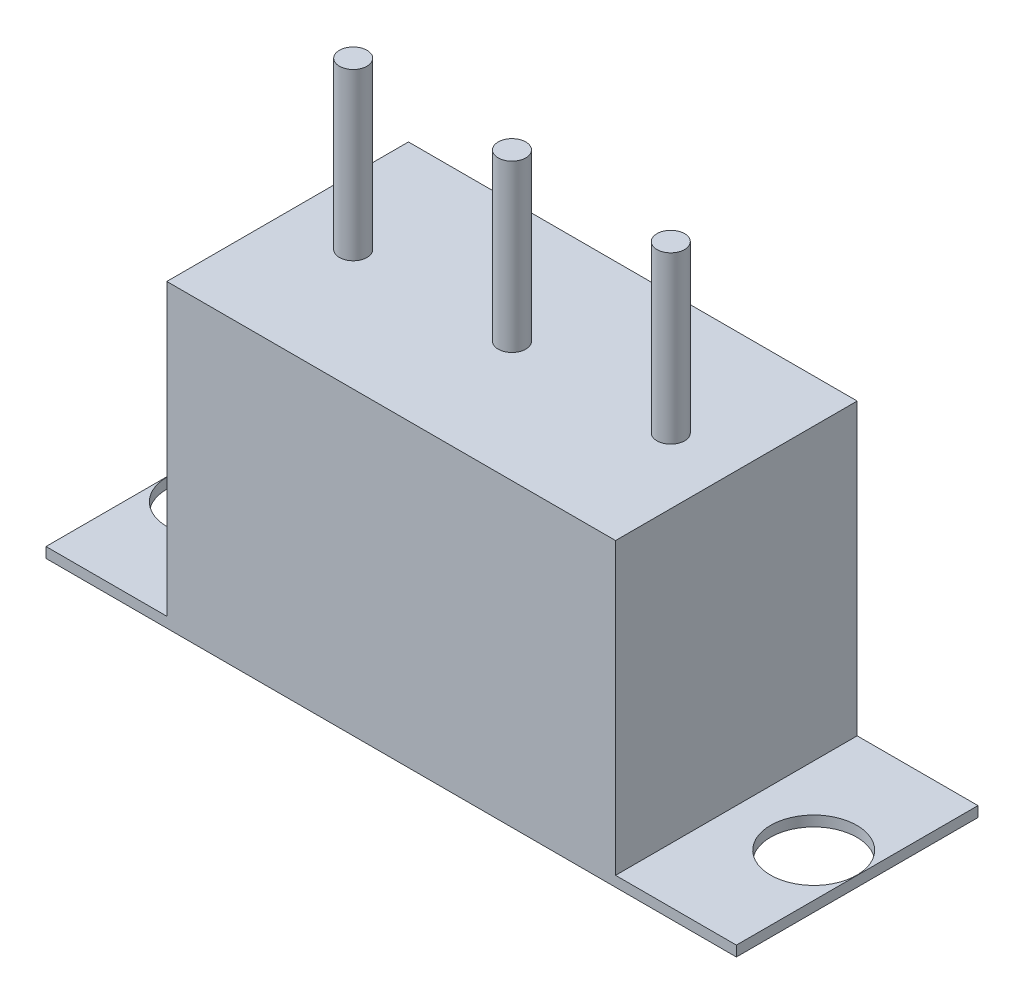
from build123d import *

# Parameters (mm, degrees)
SKETCH1_W           = 20
SKETCH1_H           = 7
BOSS_EXTRUDE1_DEPTH = 0.3
SKETCH2_W           = 13
SKETCH2_H           = 7
BOSS_EXTRUDE2_DEPTH = 8.4
CUT_EXTRUDE5_REACH  = 2.3
SKETCH3_R           = 1.25
SKETCH4_R           = 0.4
BOSS_EXTRUDE3_DEPTH = 4.8


with BuildPart() as part:
    # Sketch1 → Boss-Extrude1 (new body)
    with BuildSketch(Plane(origin=(0, 0, 0), x_dir=(1, 0, 0), z_dir=(0, 1, 0))):
        Rectangle(SKETCH1_W, SKETCH1_H)
    extrude(amount=BOSS_EXTRUDE1_DEPTH)

    # Sketch2 → Boss-Extrude2 (add)
    with BuildSketch(Plane(origin=(0, 0.3, 0), x_dir=(1, 0, 0), z_dir=(0, 1, 0))):
        Rectangle(SKETCH2_W, SKETCH2_H)
    extrude(amount=BOSS_EXTRUDE2_DEPTH)

    # Sketch3 → Cut-Extrude5 (cut, up to next)
    with BuildSketch(Plane(origin=(0, 0.3, 0), x_dir=(1, 0, 0), z_dir=(0, 1, 0)), mode=Mode.PRIVATE) as cut_extrude5_sk1:
        with Locations((-8.74, 0)):
            Circle(SKETCH3_R)
    cut_extrude5_tool1 = extrude(cut_extrude5_sk1.sketch, amount=-CUT_EXTRUDE5_REACH, mode=Mode.PRIVATE) & part.part
    add(cut_extrude5_tool1.solids().sort_by_distance((-8.74, 0.3, 0))[0], mode=Mode.SUBTRACT)
    # Sketch3 → Cut-Extrude5 (cut, up to next)
    with BuildSketch(Plane(origin=(0, 0.3, 0), x_dir=(1, 0, 0), z_dir=(0, 1, 0)), mode=Mode.PRIVATE) as cut_extrude5_sk2:
        with Locations((8.74, 0)):
            Circle(SKETCH3_R)
    cut_extrude5_tool2 = extrude(cut_extrude5_sk2.sketch, amount=-CUT_EXTRUDE5_REACH, mode=Mode.PRIVATE) & part.part
    add(cut_extrude5_tool2.solids().sort_by_distance((8.74, 0.3, 0))[0], mode=Mode.SUBTRACT)

    # Sketch4 → Boss-Extrude3 (add)
    with BuildSketch(Plane(origin=(0, 8.7, 0), x_dir=(1, 0, 0), z_dir=(0, 1, 0))):
        with Locations((-4.6, 0)):
            Circle(SKETCH4_R)
        Circle(SKETCH4_R)
        with Locations((4.6, 0)):
            Circle(SKETCH4_R)
    extrude(amount=BOSS_EXTRUDE3_DEPTH)


solid = part.part
